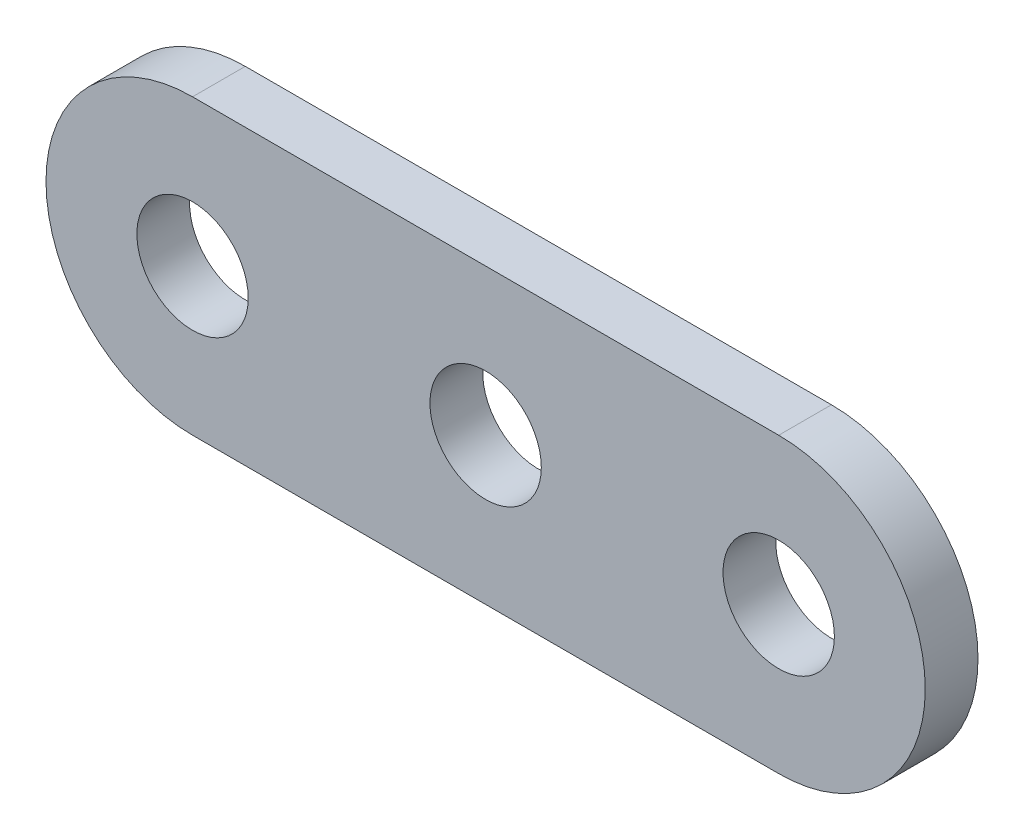
from build123d import *

# Parameters (mm, degrees)
SKETCH1_R           = 2.413
BOSS_EXTRUDE1_DEPTH = 2.286


with BuildPart() as part:
    # Sketch1 → Boss-Extrude1 (new body)
    with BuildSketch(Plane.XY):
        with BuildLine():
            Line((-12.7, 6.35), (12.7, 6.35))
            ThreePointArc((12.7, 6.35), (19.05, 0), (12.7, -6.35))
            Line((12.7, -6.35), (-12.7, -6.35))
            ThreePointArc((-12.7, -6.35), (-19.05, 0), (-12.7, 6.35))
        make_face()
        Circle(SKETCH1_R, mode=Mode.SUBTRACT)
        with Locations((12.7, 0)):
            Circle(SKETCH1_R, mode=Mode.SUBTRACT)
        with Locations((-12.7, 0)):
            Circle(SKETCH1_R, mode=Mode.SUBTRACT)
    extrude(amount=BOSS_EXTRUDE1_DEPTH)


solid = part.part
